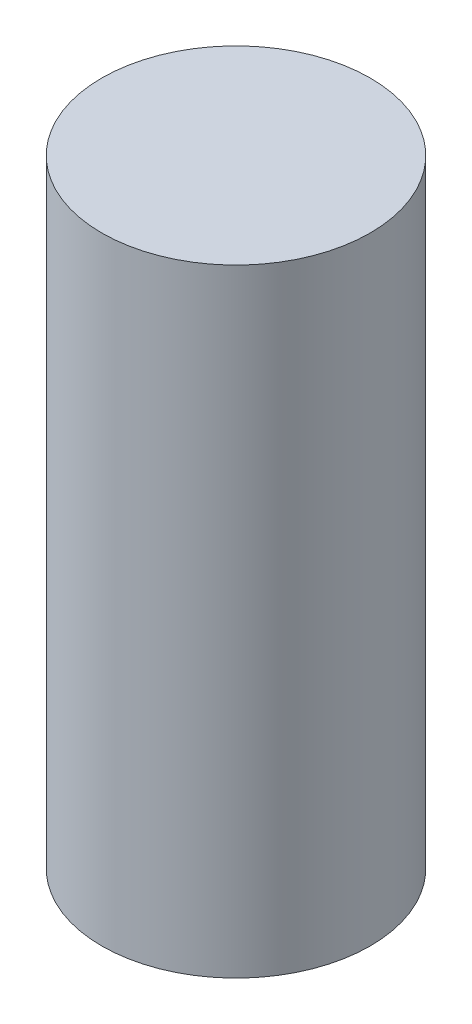
from build123d import *

# Parameters (mm, degrees)
SKETCH_1_R      = 10
EXTRUDE_1_DEPTH = 46


with BuildPart() as part:
    # Эскиз1 → Бобышка-Вытянуть1 (new body)
    with BuildSketch(Plane(origin=(0, 0, 0), x_dir=(1, 0, 0), z_dir=(0, 1, 0))):
        Circle(SKETCH_1_R)
    extrude(amount=EXTRUDE_1_DEPTH)


solid = part.part
